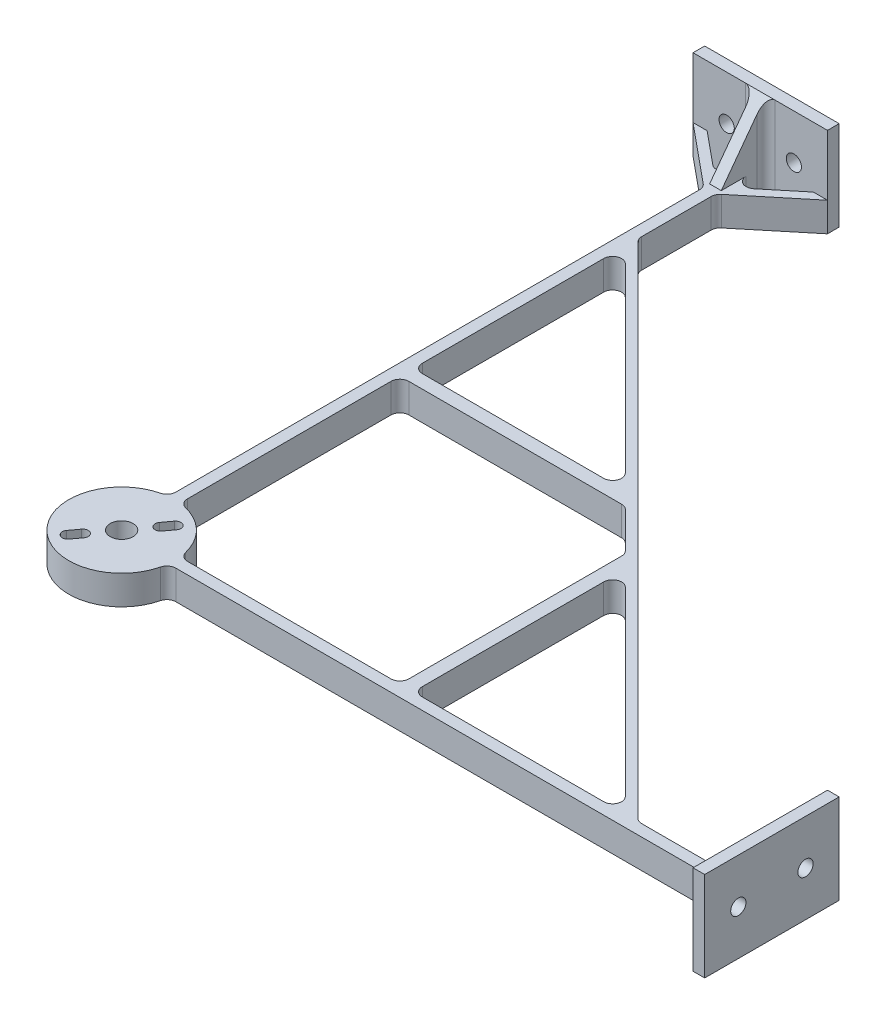
from build123d import *

# Parameters (mm, degrees)
SKETCH1_R           = 3.2385
BOSS_EXTRUDE1_DEPTH = 8.255
SKETCH3_W           = 3.302
SKETCH3_H           = 38.1
SKETCH3_W_2         = 38.1
SKETCH3_H_2         = 3.302
BOSS_EXTRUDE3_DEPTH = 25.4
SKETCH5_R           = 2.159
CUT_EXTRUDE1_DEPTH  = 204.327
SKETCH6_W           = 12.7
SKETCH6_H           = 3.302
BOSS_EXTRUDE5_DEPTH = 25.4
CUT_EXTRUDE2_DEPTH  = 25.4
SKETCH8_W           = 3.302
SKETCH8_H           = 12.7
BOSS_EXTRUDE6_DEPTH = 25.4
CUT_EXTRUDE3_DEPTH  = 25.4
FILLET1_R           = 2.54


with BuildPart() as part:
    # Sketch1 → Boss-Extrude1 (new body)
    with BuildSketch(Plane(origin=(0, 0, 0), x_dir=(1, 0, 0), z_dir=(0, 1, 0))):
        with BuildLine():
            Line((-1.651, 166.628963684), (-1.651, 14.89477744))
            ThreePointArc((-1.651, 14.89477744), (-10.596702223, -10.596702223), (14.89477744, -1.651))
            Line((14.89477744, -1.651), (166.628963684, -1.651))
            Line((166.628963684, -1.651), (180.975, -19.05))
            Line((180.975, -19.05), (180.975, -15.057345133))
            Line((180.975, -15.057345133), (169.921036316, -1.651))
            Line((169.921036316, -1.651), (180.975, -1.651))
            Line((180.975, -1.651), (180.975, 1.651))
            Line((180.975, 1.651), (169.921036316, 1.651))
            Line((169.921036316, 1.651), (180.975, 15.057345133))
            Line((180.975, 15.057345133), (180.975, 19.05))
            Line((180.975, 19.05), (166.628963684, 1.651))
            Line((166.628963684, 1.651), (144.671051224, 1.651))
            Line((144.671051224, 1.651), (1.651, 144.671051224))
            Line((1.651, 144.671051224), (1.651, 166.628963684))
            Line((1.651, 166.628963684), (19.05, 180.975))
            Line((19.05, 180.975), (15.057345133, 180.975))
            Line((15.057345133, 180.975), (1.651, 169.921036316))
            Line((1.651, 169.921036316), (1.651, 180.975))
            Line((1.651, 180.975), (-1.651, 180.975))
            Line((-1.651, 180.975), (-1.651, 169.921036316))
            Line((-1.651, 169.921036316), (-15.057345133, 180.975))
            Line((-15.057345133, 180.975), (-19.05, 180.975))
            Line((-19.05, 180.975), (-1.651, 166.628963684))
        make_face()
        with BuildLine():
            Line((-7.721732332, -7.873214705), (-5.908712478, -5.423058993))
            ThreePointArc((-5.908712478, -5.423058993), (-3.777124696, -5.104491065), (-3.458556767, -7.236078848))
            Line((-3.458556767, -7.236078848), (-5.271576621, -9.686234559))
            ThreePointArc((-5.271576621, -9.686234559), (-7.403164404, -10.004802487), (-7.721732332, -7.873214705))
        make_face(mode=Mode.SUBTRACT)
        Circle(SKETCH1_R, mode=Mode.SUBTRACT)
        with BuildLine():
            ThreePointArc((5.908712478, 5.423058993), (3.777124696, 5.104491065), (3.458556767, 7.236078848))
            Line((3.458556767, 7.236078848), (5.271576621, 9.686234559))
            ThreePointArc((5.271576621, 9.686234559), (7.403164404, 10.004802487), (7.721732332, 7.873214705))
            Line((7.721732332, 7.873214705), (5.908712478, 5.423058993))
        make_face(mode=Mode.SUBTRACT)
        with BuildLine():
            Line((77.202140867, 1.651), (14.89477744, 1.651))
            ThreePointArc((14.89477744, 1.651), (10.596702223, 10.596702223), (1.651, 14.89477744))
            Line((1.651, 14.89477744), (1.651, 77.202140867))
            Line((1.651, 77.202140867), (65.527807909, 77.202140867))
            Line((65.527807909, 77.202140867), (77.202140867, 65.527807909))
            Line((77.202140867, 65.527807909), (77.202140867, 1.651))
        make_face(mode=Mode.SUBTRACT)
        Polygon((141.078948776, 1.651), (81.012140867, 1.651), (81.012140867, 61.717807909), align=None, mode=Mode.SUBTRACT)
        Polygon((1.651, 81.012140867), (1.651, 141.078948776), (61.717807909, 81.012140867), align=None, mode=Mode.SUBTRACT)
    extrude(amount=BOSS_EXTRUDE1_DEPTH)

    # Sketch3 → Boss-Extrude3 (add)
    with BuildSketch(Plane(origin=(0, 0, 0), x_dir=(1, 0, 0), z_dir=(0, 1, 0))):
        with Locations((182.626, 0)):
            Rectangle(SKETCH3_W, SKETCH3_H)
        with Locations((0, 182.626)):
            Rectangle(SKETCH3_W_2, SKETCH3_H_2)
    extrude(amount=BOSS_EXTRUDE3_DEPTH)

    # Sketch5 → Cut-Extrude1 (cut, through all)
    with BuildSketch(Plane(origin=(184.277, 0, 0), x_dir=(0, 0, -1), z_dir=(1, 0, 0))):
        with Locations((-9.525, 12.7)):
            Circle(SKETCH5_R)
        with Locations((9.525, 12.7)):
            Circle(SKETCH5_R)
    cut_extrude1 = extrude(amount=-CUT_EXTRUDE1_DEPTH, mode=Mode.SUBTRACT)

    # Mirror1: Cut-Extrude1 across plane
    add(cut_extrude1.mirror(Plane(origin=(0, 0, 0), x_dir=(-0.707106781, 0, 0.707106781), z_dir=(0.707106781, 0, 0.707106781))), mode=Mode.SUBTRACT)

    # Sketch6 → Boss-Extrude5 (add)
    with BuildSketch(Plane(origin=(0, 0, 0), x_dir=(1, 0, 0), z_dir=(0, 1, 0))):
        with Locations((174.625, 0)):
            Rectangle(SKETCH6_W, SKETCH6_H)
    extrude(amount=BOSS_EXTRUDE5_DEPTH)

    # Sketch7 → Cut-Extrude2 (cut)
    with BuildSketch(Plane(origin=(0, 0, -1.651), x_dir=(-1, 0, 0), z_dir=(0, 0, -1))):
        Polygon((-180.975, 25.4), (-168.275, 8.255), (-168.275, 25.4), align=None)
    extrude(amount=-CUT_EXTRUDE2_DEPTH, mode=Mode.SUBTRACT)

    # Sketch8 → Boss-Extrude6 (add)
    with BuildSketch(Plane(origin=(0, 0, 0), x_dir=(1, 0, 0), z_dir=(0, 1, 0))):
        with Locations((0, 174.625)):
            Rectangle(SKETCH8_W, SKETCH8_H)
    extrude(amount=BOSS_EXTRUDE6_DEPTH)

    # Sketch9 → Cut-Extrude3 (cut)
    with BuildSketch(Plane(origin=(1.651, 0, 0), x_dir=(0, 0, -1), z_dir=(1, 0, 0))):
        Polygon((180.975, 25.4), (168.275, 8.255), (168.275, 25.4), align=None)
    extrude(amount=-CUT_EXTRUDE3_DEPTH, mode=Mode.SUBTRACT)

    # Fillet1
    fillet1_edges = [part.edges().sort_by_distance(p)[0] for p in [
        (-1.651, 4.1275, -166.628963684),
        (-1.651, 4.1275, -169.921036316),
        (-1.651, 12.7, -180.975),
        (1.651, 12.7, -180.975),
        (1.651, 4.1275, -169.921036316),
        (1.651, 4.1275, -166.628963684),
        (1.651, 4.1275, -144.671051224),
        (144.671051224, 4.1275, -1.651),
        (166.628963684, 4.1275, -1.651),
        (169.921036316, 4.1275, -1.651),
        (180.975, 12.7, -1.651),
        (180.975, 12.7, 1.651),
        (169.921036316, 4.1275, 1.651),
        (166.628963684, 4.1275, 1.651),
        (14.89477744, 4.1275, 1.651),
        (-1.651, 4.1275, -14.89477744),
        (61.717807909, 4.1275, -81.012140867),
        (1.651, 4.1275, -141.078948776),
        (1.651, 4.1275, -81.012140867),
        (77.202140867, 4.1275, -1.651),
        (77.202140867, 4.1275, -65.527807909),
        (65.527807909, 4.1275, -77.202140867),
        (1.651, 4.1275, -77.202140867),
        (1.651, 4.1275, -14.89477744),
        (14.89477744, 4.1275, -1.651),
        (141.078948776, 4.1275, -1.651),
        (81.012140867, 4.1275, -61.717807909),
        (81.012140867, 4.1275, -1.651),
    ]]
    fillet(fillet1_edges, radius=FILLET1_R)


solid = part.part
